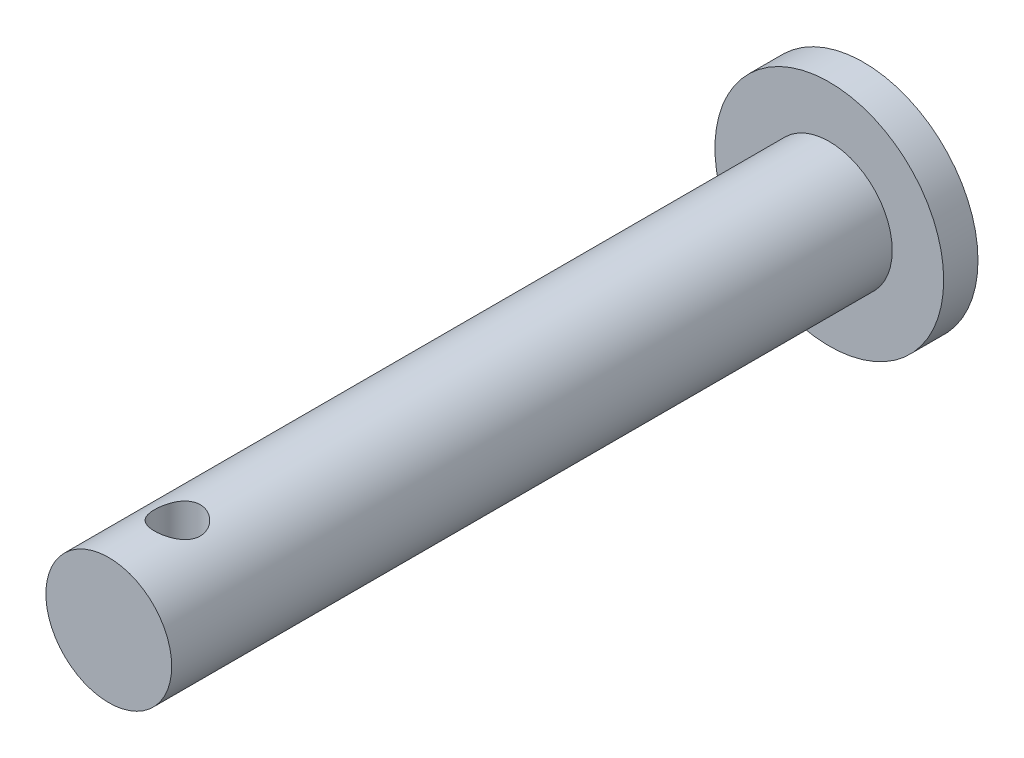
from build123d import *

# Parameters (mm, degrees)
SKETCH1_R           = 5
BOSS_EXTRUDE1_DEPTH = 1.5
SKETCH2_R           = 2.75
BOSS_EXTRUDE2_DEPTH = 33
SKETCH3_R           = 1
CUT_EXTRUDE1_DEPTH  = 6


with BuildPart() as part:
    # Sketch1 → Boss-Extrude1 (new body)
    with BuildSketch(Plane.XY):
        Circle(SKETCH1_R)
    extrude(amount=BOSS_EXTRUDE1_DEPTH)

    # Sketch2 → Boss-Extrude2 (add)
    with BuildSketch(Plane.XY):
        Circle(SKETCH2_R)
    extrude(amount=BOSS_EXTRUDE2_DEPTH)

    # Sketch3 → Cut-Extrude1 (cut, through all)
    with BuildSketch(Plane(origin=(0, 0, 0), x_dir=(1, 0, 0), z_dir=(0, 1, 0))):
        with Locations((0, -30)):
            Circle(SKETCH3_R)
    extrude(amount=CUT_EXTRUDE1_DEPTH, mode=Mode.SUBTRACT)


solid = part.part
